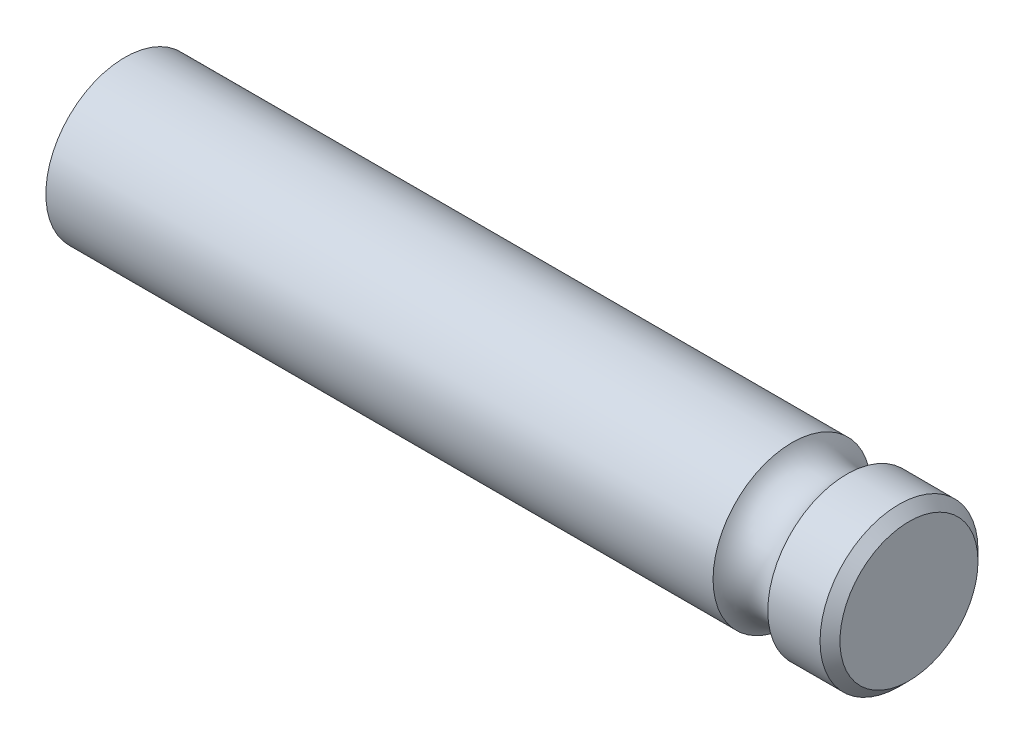
from build123d import *

# Parameters (mm, degrees)
SKETCH1_R      = 7.9375
EXTRUDE1_DEPTH = 78.8
SKETCH2_R      = 3.175
CHAMFER1_SIZE  = 1


with BuildPart() as part:
    # Sketch1 → Extrude1 (new body)
    with BuildSketch(Plane(origin=(0, 0, 0), x_dir=(0, 0, -1), z_dir=(1, 0, 0))):
        Circle(SKETCH1_R)
    extrude(amount=EXTRUDE1_DEPTH)

    # Sketch2 → Cut-Revolve1 (revolve, cut)
    with BuildSketch(Plane(origin=(0, 0, 0), x_dir=(1, 0, 0), z_dir=(0, 1, 0))):
        with Locations((69.8, 9.525)):
            Circle(SKETCH2_R)
    revolve(axis=Axis((0, 0, 0), (1, 0, 0)), mode=Mode.SUBTRACT)

    # Chamfer1
    chamfer1_edges = [part.edges().sort_by_distance(p)[0] for p in [
        (78.8, 0, 7.9375),
    ]]
    chamfer(chamfer1_edges, length=CHAMFER1_SIZE)


solid = part.part
